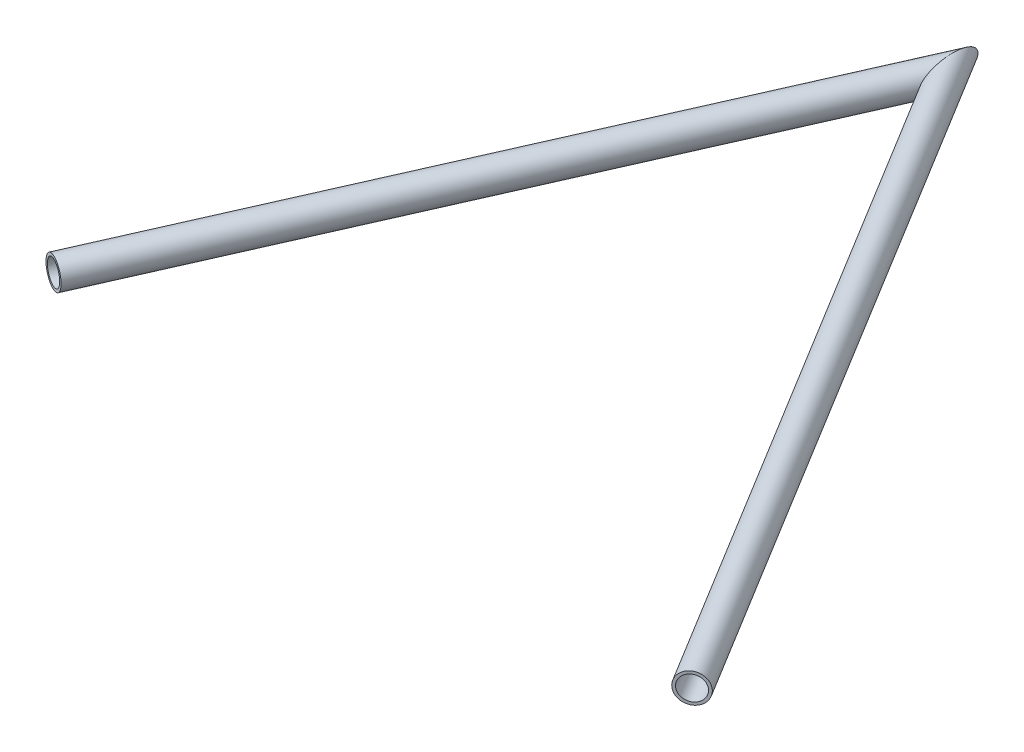
from build123d import *

# Parameters (mm, degrees)
SKETCH1_ON_SEGMENT_1_R          = 7.9375
SKETCH1_ON_SEGMENT_1_R_2        = 6.4643
STRUCTURAL_MEMBER1_DEPTH        = 439.056418566
SKETCH1_R                       = 7.9375
SKETCH1_R_2                     = 6.4643
STRUCTURAL_MEMBER1_2_DEPTH      = 364.637720715
STRUCTURAL_MEMBER1_2_DEPTH_BACK = 22.41356204


with BuildPart() as part:
    # Sketch1 on segment 1 (carried to segment 1) → Structural Member1 (new body)
    with BuildSketch(Plane(origin=(217.552437832, 0, 355.333936864), x_dir=(-0.852850184, 0, 0.522155689), z_dir=(-0.522155689, 0, -0.852850184))):
        Circle(SKETCH1_ON_SEGMENT_1_R)
        Circle(SKETCH1_ON_SEGMENT_1_R_2, mode=Mode.SUBTRACT)
    extrude(amount=STRUCTURAL_MEMBER1_DEPTH)

    # Structural Member1 mitre 1
    split(bisect_by=Plane(origin=(0, 0, 0), x_dir=(0, 1, 0), z_dir=(0.997786708, 0, -0.066495754)), keep=Keep.TOP)


with BuildPart() as body_2:
    # Sketch1 → Structural Member1 2 (new, two sides)
    with BuildSketch(Plane(origin=(0, 0, 0), x_dir=(0.9145966900221395, 0, 0.40436727686664553), z_dir=(-0.4043672768666456, 0, 0.9145966900221396))) as structural_member1_2_sk:
        Circle(SKETCH1_R)
        Circle(SKETCH1_R_2, mode=Mode.SUBTRACT)
    extrude(amount=STRUCTURAL_MEMBER1_2_DEPTH)
    extrude(structural_member1_2_sk.sketch, amount=-STRUCTURAL_MEMBER1_2_DEPTH_BACK)

    # Structural Member1 2 mitre 1
    split(bisect_by=Plane(origin=(0, 0, 0), x_dir=(0, -1, 0), z_dir=(-0.997786708, 0, 0.066495754)), keep=Keep.TOP)


solid = Compound([part.part, body_2.part])
